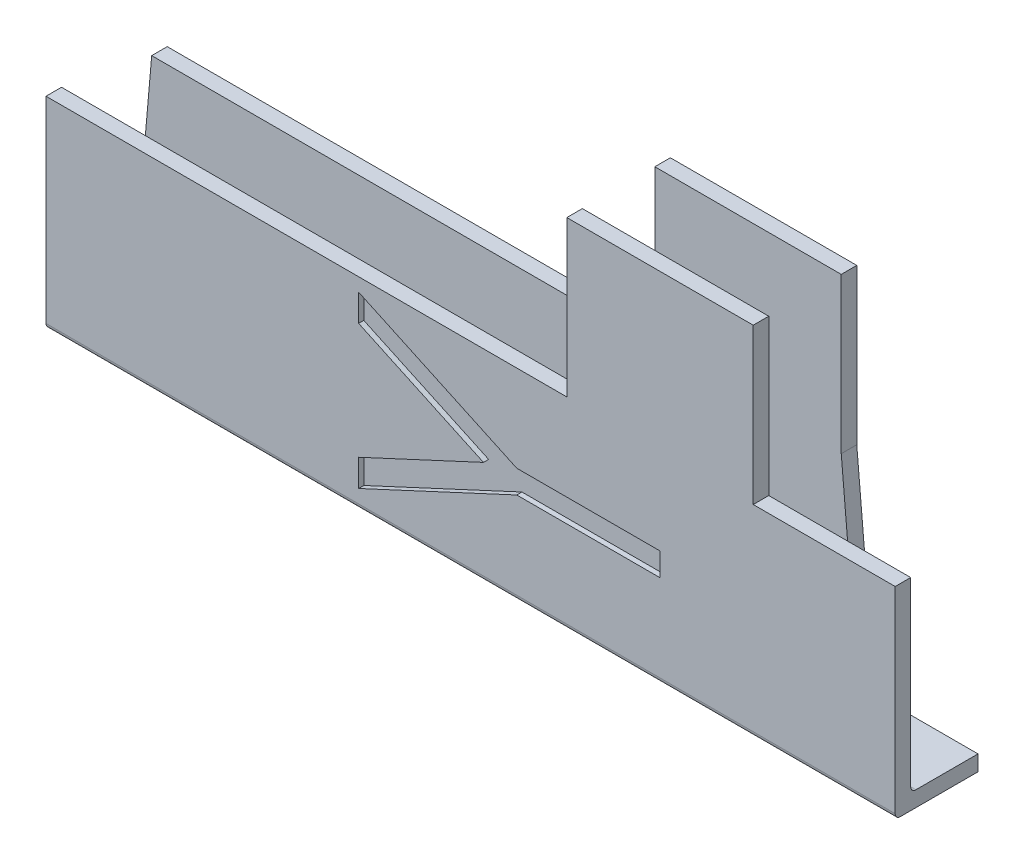
from build123d import *

# Parameters (mm, degrees)
IZIM1_W                     = 70
IZIM1_H                     = 19.5
Y_KSEKLIK_EKSTR_ZYON1_DEPTH = 10
BO_ALTMA1_T                 = -1.5
RADYUS1_R                   = 0.5
RADYUS2_R                   = 0.5
KES_EKSTR_ZYON1_DEPTH       = 2
Y_KSEKLIK_EKSTR_ZYON3_DEPTH = 10
IZIM8_W                     = 18
IZIM8_H                     = 1.5
Y_KSEKLIK_EKSTR_ZYON4_DEPTH = 15
KES_EKSTR_ZYON3_DEPTH       = 10
IZIM10_W                    = 1.5
IZIM10_H                    = 15
KES_EKSTR_ZYON4_DEPTH       = 18
KES_EKSTR_ZYON5_DEPTH       = 0.5
Y_KSEKLIK_EKSTR_ZYON5_DEPTH = 2


with BuildPart() as part:
    # Çizim1 → Yükseklik-Ekstrüzyon1 (new body)
    with BuildSketch(Plane.XY):
        Rectangle(IZIM1_W, IZIM1_H)
    extrude(amount=Y_KSEKLIK_EKSTR_ZYON1_DEPTH)

    # İç Boşaltma1
    bo_altma1_openings = [part.faces().sort_by_distance(p)[0] for p in [
        (-35, 0, 5),
        (0, 9.75, 5),
        (35, 0, 5),
    ]]
    offset(amount=BO_ALTMA1_T, openings=bo_altma1_openings, kind=Kind.INTERSECTION)

    # Radyus1
    radyus1_edges = [part.edges().sort_by_distance(p)[0] for p in [
        (0, -8.25, 1.5),
        (0, -8.25, 8.5),
    ]]
    fillet(radyus1_edges, radius=RADYUS1_R)

    # Radyus2
    radyus2_edges = [part.edges().sort_by_distance(p)[0] for p in [
        (0, -9.75, 10),
        (0, -9.75, 0),
    ]]
    fillet(radyus2_edges, radius=RADYUS2_R)

    # Çizim2 → Kes-Ekstrüzyon1 (cut)
    with BuildSketch(Plane(origin=(0, 0, 0), x_dir=(-1, 0, 0), z_dir=(0, 0, -1))):
        Polygon((35, -9.75), (33.293971061, 9.75), (35, 9.75), align=None)
    kes_ekstr_zyon1 = extrude(amount=-KES_EKSTR_ZYON1_DEPTH, mode=Mode.SUBTRACT)

    # Aynalama1: Kes-Ekstrüzyon1 across plane
    add(kes_ekstr_zyon1.mirror(Plane(origin=(0, 0, 0), x_dir=(0, 0, 1), z_dir=(1, 0, 0))), mode=Mode.SUBTRACT)

    # Çizim7 → Yükseklik-Ekstrüzyon3 (add)
    with BuildSketch(Plane.ZY.offset(35)):
        with BuildLine():
            Line((2, -8.25), (2, -9.75))
            Line((2, -9.75), (9.5, -9.75))
            ThreePointArc((9.5, -9.75), (9.853553391, -9.603553391), (10, -9.25))
            Line((10, -9.25), (10, 9.75))
            Line((10, 9.75), (8.5, 9.75))
            Line((8.5, 9.75), (8.5, -7.75))
            ThreePointArc((8.5, -7.75), (8.353553391, -8.103553391), (8, -8.25))
            Line((8, -8.25), (2, -8.25))
        make_face()
    y_kseklik_ekstr_zyon3 = extrude(amount=Y_KSEKLIK_EKSTR_ZYON3_DEPTH)

    # Çizim8 → Yükseklik-Ekstrüzyon4 (add)
    with BuildSketch(Plane(origin=(0, 9.75, 0), x_dir=(1, 0, 0), z_dir=(0, 1, 0))):
        with Locations((-24.293971061, -0.75)):
            Rectangle(IZIM8_W, IZIM8_H)
        with Locations((-24.293971061, -9.25)):
            Rectangle(IZIM8_W, IZIM8_H)
    y_kseklik_ekstr_zyon4 = extrude(amount=Y_KSEKLIK_EKSTR_ZYON4_DEPTH)

    # Aynalama3: Yükseklik-Ekstrüzyon3, Yükseklik-Ekstrüzyon4 across plane
    add(y_kseklik_ekstr_zyon3.mirror(Plane(origin=(0, 0, 0), x_dir=(0, 0, 1), z_dir=(1, 0, 0))))
    add(y_kseklik_ekstr_zyon4.mirror(Plane(origin=(0, 0, 0), x_dir=(0, 0, 1), z_dir=(1, 0, 0))))

    # Çizim9 → Kes-Ekstrüzyon3 (cut)
    with BuildSketch(Plane.ZY.offset(45)):
        with BuildLine():
            Line((2, -9.75), (9.5, -9.75))
            ThreePointArc((9.5, -9.75), (9.853553391, -9.603553391), (10, -9.25))
            Line((10, -9.25), (10, 9.75))
            Line((10, 9.75), (8.5, 9.75))
            Line((8.5, 9.75), (8.5, -7.75))
            ThreePointArc((8.5, -7.75), (8.353553391, -8.103553391), (8, -8.25))
            Line((8, -8.25), (2, -8.25))
            Line((2, -8.25), (2, -9.75))
        make_face()
    extrude(amount=-KES_EKSTR_ZYON3_DEPTH, mode=Mode.SUBTRACT)

    # Çizim10 → Kes-Ekstrüzyon4 (cut)
    with BuildSketch(Plane.ZY.offset(33.293971061)):
        with Locations((0.75, 17.25)):
            Rectangle(IZIM10_W, IZIM10_H)
        with Locations((9.25, 17.25)):
            Rectangle(IZIM10_W, IZIM10_H)
    extrude(amount=-KES_EKSTR_ZYON4_DEPTH, mode=Mode.SUBTRACT)

    # Çizim11 → Kes-Ekstrüzyon5 (cut)
    with BuildSketch(Plane.XY.offset(10)):
        Polygon((-4.810195605, 8.458867521), (-4.810195605, 5.846955128), (7.246578567, 0.25), (-4.810195605, -5.346955128), (-4.810195605, -7.958867521), (10.458997604, -0.869391026), (24.293971061, -0.869391026), (24.293971061, 1.369391026), (10.458997604, 1.369391026), align=None)
    kes_ekstr_zyon5 = extrude(amount=-KES_EKSTR_ZYON5_DEPTH, mode=Mode.SUBTRACT)

    # Aynalama4: Kes-Ekstrüzyon5 across plane
    add(kes_ekstr_zyon5.mirror(Plane.XY.offset(5)), mode=Mode.SUBTRACT)

    # Çizim12 → Yükseklik-Ekstrüzyon5 (add)
    with BuildSketch(Plane(origin=(45, 0, 0), x_dir=(0, 0, -1), z_dir=(1, 0, 0))):
        with BuildLine():
            Line((-9.5, -9.75), (-2, -9.75))
            Line((-2, -9.75), (-2, -8.25))
            Line((-2, -8.25), (-8, -8.25))
            ThreePointArc((-8, -8.25), (-8.353553391, -8.103553391), (-8.5, -7.75))
            Line((-8.5, -7.75), (-8.5, 9.75))
            Line((-8.5, 9.75), (-10, 9.75))
            Line((-10, 9.75), (-10, -9.25))
            ThreePointArc((-10, -9.25), (-9.853553391, -9.603553391), (-9.5, -9.75))
        make_face()
    extrude(amount=Y_KSEKLIK_EKSTR_ZYON5_DEPTH)


solid = part.part
